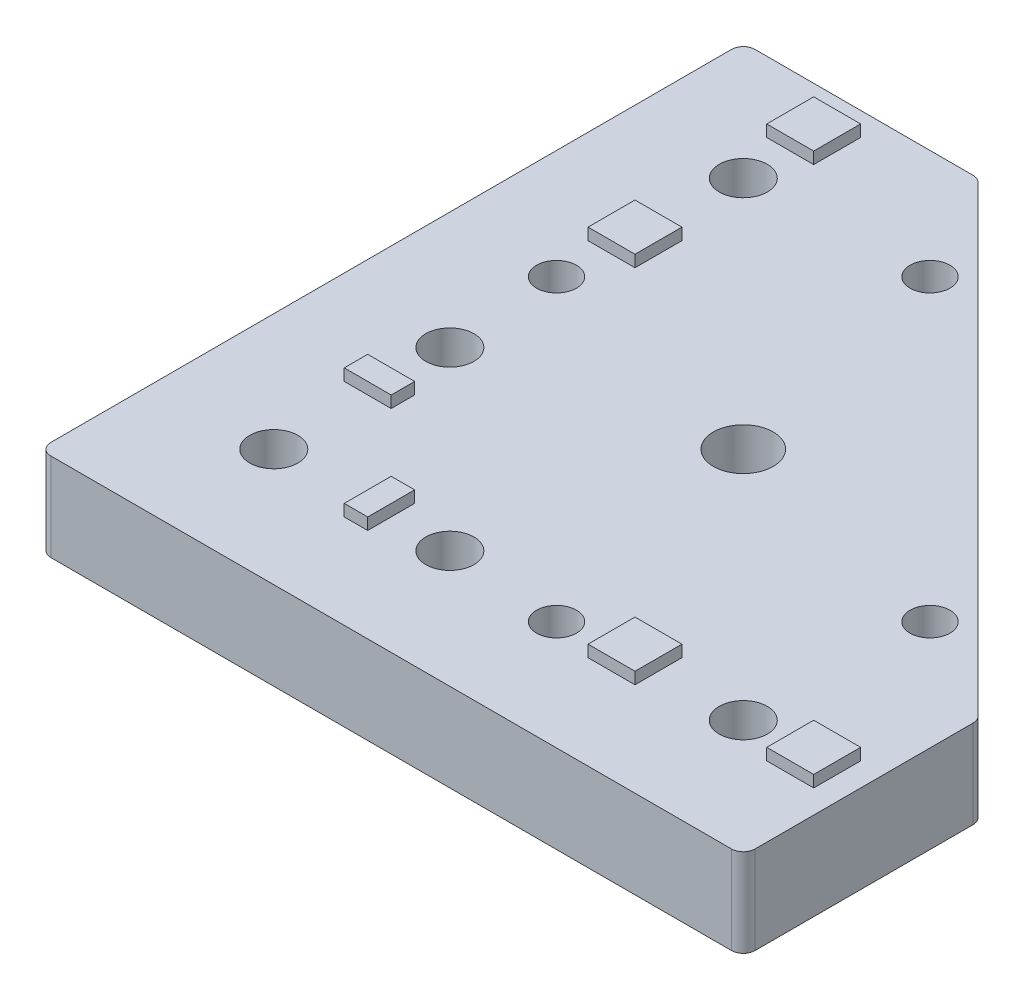
from build123d import *

# Parameters (mm, degrees)
EXTRUDE_1_DEPTH             = 15
HOLE_WIZARD_M121_D          = 10.2
HOLE_WIZARD_M121_DEPTH      = 15
HOLE_WIZARD_M81_D           = 6.8
HOLE_WIZARD_M81_DEPTH       = 15
HOLE_WIZARD_8_2_8_2_1_D     = 8.2
HOLE_WIZARD_8_2_8_2_1_DEPTH = 15
SKETCH_9_W                  = 8
SKETCH_9_H                  = 8
SKETCH_9_H_2                = 4
SKETCH_9_W_2                = 4
EXTRUDE_2_DEPTH             = 2
FILLET_1_R                  = 2


with BuildPart() as part:
    # Эскиз1 → Бобышка-Вытянуть1 (new body)
    with BuildSketch(Plane(origin=(0, 0, 0), x_dir=(1, 0, 0), z_dir=(0, 1, 0))):
        Polygon((0, 0), (0, 120), (40, 120), (120, 40), (120, 0), align=None)
    extrude(amount=EXTRUDE_1_DEPTH)

    # Отверстие обработанное метчиком M121
    with Locations(Plane(origin=(0, 15, 0), x_dir=(1, 0, 0), z_dir=(0, 1, 0))):
        with Locations((60, 60)):
            Hole(HOLE_WIZARD_M121_D / 2, depth=HOLE_WIZARD_M121_DEPTH)

    # Отверстие обработанное метчиком M81
    with Locations(Plane(origin=(0, 15, 0), x_dir=(1, 0, 0), z_dir=(0, 1, 0))):
        with Locations((50.454058454, 101.365746699), (101.365746699, 50.454058454), (69.545941546, 18.634253301), (18.634253301, 69.545941546)):
            Hole(HOLE_WIZARD_M81_D / 2, depth=HOLE_WIZARD_M81_DEPTH)

    # Диаметр отверстия Ø8.2 (8.2)1
    with Locations(Plane(origin=(0, 15, 0), x_dir=(1, 0, 0), z_dir=(0, 1, 0))):
        with Locations((20, 100), (20, 50), (20, 20), (50, 20), (100, 20)):
            Hole(HOLE_WIZARD_8_2_8_2_1_D / 2, depth=HOLE_WIZARD_8_2_8_2_1_DEPTH)

    # Эскиз9 → Бобышка-Вытянуть2 (add)
    with BuildSketch(Plane(origin=(0, 15, 0), x_dir=(1, 0, 0), z_dir=(0, 1, 0))):
        with Locations((20, 112)):
            Rectangle(SKETCH_9_W, SKETCH_9_H)
        with Locations((20, 81.545941546)):
            Rectangle(SKETCH_9_W, SKETCH_9_H)
        with Locations((20, 38)):
            Rectangle(SKETCH_9_W, SKETCH_9_H_2)
        with Locations((38, 20)):
            Rectangle(SKETCH_9_W_2, SKETCH_9_H)
        with Locations((81.545941546, 20)):
            Rectangle(SKETCH_9_W, SKETCH_9_H)
        with Locations((112, 20)):
            Rectangle(SKETCH_9_W, SKETCH_9_H)
    extrude(amount=EXTRUDE_2_DEPTH)

    # Скругление1
    fillet_1_edges = [part.edges().sort_by_distance(p)[0] for p in [
        (0, 7.5, 0),
        (0, 7.5, -120),
        (40, 7.5, -120),
        (120, 7.5, -40),
        (120, 7.5, 0),
    ]]
    fillet(fillet_1_edges, radius=FILLET_1_R)


solid = part.part
